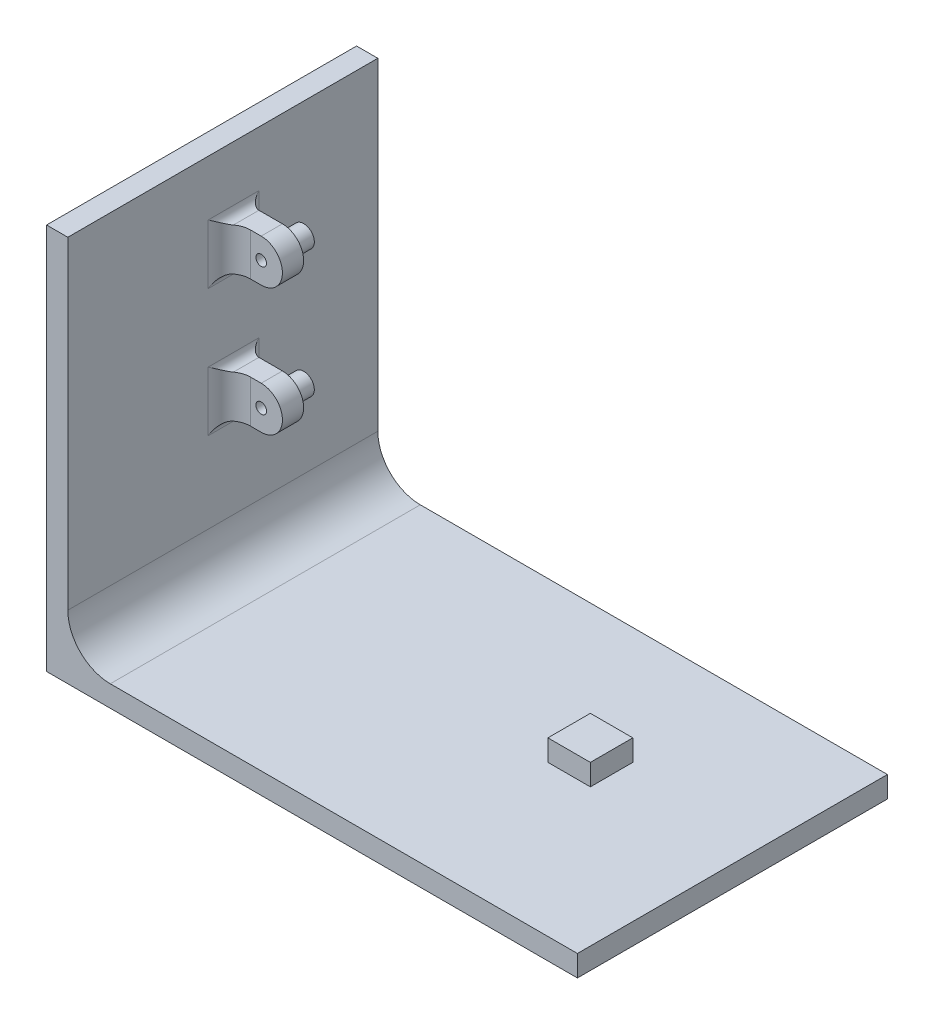
from build123d import *

# Parameters (mm, degrees)
SCHIZZO1_W                   = 5
SCHIZZO1_H                   = 70
ESTRUSIONE_ESTRUSIONE1_DEPTH = 70
ESTRUSIONE_ESTRUSIONE2_START = -35
ESTRUSIONE_ESTRUSIONE2_DEPTH = 5
SCHIZZO3_R                   = 2.5
ESTRUSIONE_ESTRUSIONE3_DEPTH = 5
SCHIZZO4_W                   = 130
SCHIZZO4_H                   = 70
ESTRUSIONE_ESTRUSIONE4_DEPTH = 5
SCHIZZO5_R                   = 1.25
TAGLIO_ESTRUSIONE1_DEPTH     = 46
ESTRUSIONE_ESTRUSIONE5_DEPTH = 3
RACCORDO1_R                  = 5
RACCORDO2_R                  = 5
RACCORDO3_R                  = 2
RACCORDO4_R                  = 2
TAGLIO_ESTRUSIONE2_REACH     = 75
SCHIZZO8_R                   = 1.25
SCHIZZO8_W                   = 144.941268382
SCHIZZO8_H                   = 14.939772921
TAGLIO_ESTRUSIONE3_DEPTH     = 74
SCHIZZO10_W                  = 5
SCHIZZO10_H                  = 73
ESTRUSIONE_ESTRUSIONE6_DEPTH = 31
SCHIZZO11_W                  = 73
SCHIZZO11_H                  = 5
ESTRUSIONE_ESTRUSIONE7_DEPTH = 120
RACCORDO5_R                  = 10
SCHIZZO12_W                  = 10
SCHIZZO12_H                  = 10
ESTRUSIONE_ESTRUSIONE8_DEPTH = 5


with BuildPart() as part:
    # Schizzo1 → Estrusione-Estrusione1 (new body)
    with BuildSketch(Plane.XY):
        with Locations((-2.5, 35)):
            Rectangle(SCHIZZO1_W, SCHIZZO1_H)
    extrude(amount=ESTRUSIONE_ESTRUSIONE1_DEPTH)

    # Schizzo2 → Estrusione-Estrusione2 (add)
    with BuildSketch(Plane.XY.offset(70).offset(ESTRUSIONE_ESTRUSIONE2_START)):
        with BuildLine():
            Line((0, 50), (0, 45))
            Line((0, 45), (7.531619243, 45))
            ThreePointArc((7.531619243, 45), (12.531619243, 50), (7.531619243, 55))
            Line((7.531619243, 55), (0, 55))
            Line((0, 55), (0, 50))
        make_face()
        with BuildLine():
            Line((0, 20), (0, 15))
            Line((0, 15), (7.531619243, 15))
            ThreePointArc((7.531619243, 15), (12.531619243, 20), (7.531619243, 25))
            Line((7.531619243, 25), (0, 25))
            Line((0, 25), (0, 20))
        make_face()
    extrude(amount=-ESTRUSIONE_ESTRUSIONE2_DEPTH)

    # Schizzo3 → Estrusione-Estrusione3 (add)
    with BuildSketch(Plane(origin=(0, 0, 30), x_dir=(-1, 0, 0), z_dir=(0, 0, -1))):
        with Locations((-7.547600082, 50.061310314)):
            Circle(SCHIZZO3_R)
        with Locations((-7.547600082, 19.939772921)):
            Circle(SCHIZZO3_R)
    extrude(amount=ESTRUSIONE_ESTRUSIONE3_DEPTH)

    # Schizzo4 → Estrusione-Estrusione4 (add)
    with BuildSketch(Plane.XZ):
        with Locations((60, 35)):
            Rectangle(SCHIZZO4_W, SCHIZZO4_H)
    extrude(amount=ESTRUSIONE_ESTRUSIONE4_DEPTH)

    # Schizzo5 → Taglio-Estrusione1 (cut, through all)
    with BuildSketch(Plane(origin=(0, 0, 25), x_dir=(-1, 0, 0), z_dir=(0, 0, -1))):
        with Locations((-7.547600082, 50.061310314)):
            Circle(SCHIZZO5_R)
        with Locations((-7.547600082, 19.939772921)):
            Circle(SCHIZZO5_R)
    extrude(amount=-TAGLIO_ESTRUSIONE1_DEPTH, mode=Mode.SUBTRACT)

    # Schizzo6 → Estrusione-Estrusione5 (add)
    with BuildSketch(Plane.XY.offset(70)):
        Polygon((125, 0), (0, 0), (0, 70), (-5, 70), (-5, -5), (125, -5), align=None)
        Polygon((0, 70), (125, 0), (0, 0), align=None)
    extrude(amount=ESTRUSIONE_ESTRUSIONE5_DEPTH)

    # Raccordo1
    raccordo1_edges = [part.edges().sort_by_distance(p)[0] for p in [
        (0, 35, 70),
        (62.5, 0, 70),
        (0, 0, 35),
    ]]
    fillet(raccordo1_edges, radius=RACCORDO1_R)

    # Raccordo2
    raccordo2_edges = [part.edges().sort_by_distance(p)[0] for p in [
        (0, 50, 35),
        (0, 20, 35),
    ]]
    fillet(raccordo2_edges, radius=RACCORDO2_R)

    # Raccordo3
    raccordo3_edges = [part.edges().sort_by_distance(p)[0] for p in [
        (0, 50, 30),
        (0, 20, 30),
    ]]
    fillet(raccordo3_edges, radius=RACCORDO3_R)

    # Raccordo4
    raccordo4_edges = [part.edges().sort_by_distance(p)[0] for p in [
        (0, 25, 32.5),
        (0, 15, 32.5),
        (0, 45, 32.5),
        (0, 55, 32.5),
    ]]
    fillet(raccordo4_edges, radius=RACCORDO4_R)

    # Schizzo7 → Taglio-Estrusione2 (cut, up to next)
    with BuildSketch(Plane(origin=(0, 0, 73), x_dir=(-1, 0, 0), z_dir=(0, 0, -1)), mode=Mode.PRIVATE) as taglio_estrusione2_sk1:
        with BuildLine():
            ThreePointArc((-5, 0), (-1.464466094, 1.464466094), (0, 5))
            Line((0, 5), (0, 70))
            Line((0, 70), (-125, 0))
            Line((-125, 0), (-5, 0))
        make_face()
    taglio_estrusione2_tool1 = extrude(taglio_estrusione2_sk1.sketch, amount=TAGLIO_ESTRUSIONE2_REACH, mode=Mode.PRIVATE) & part.part
    add(taglio_estrusione2_tool1.solids().sort_by_distance((41.716454, 23.360611, 73))[0], mode=Mode.SUBTRACT)

    # Schizzo8 → Taglio-Estrusione3 (cut, through all)
    with BuildSketch(Plane(origin=(0, 0, 0), x_dir=(-1, 0, 0), z_dir=(0, 0, -1))):
        with Locations((-7.547600082, 19.939772921)):
            Circle(SCHIZZO8_R)
        with Locations((-52.529365809, 2.469886461)):
            Rectangle(SCHIZZO8_W, SCHIZZO8_H)
    extrude(amount=-TAGLIO_ESTRUSIONE3_DEPTH, mode=Mode.SUBTRACT)

    # Schizzo10 → Estrusione-Estrusione6 (add)
    with BuildSketch(Plane.XZ.offset(-9.939772921)):
        with Locations((-2.5, 36.5)):
            Rectangle(SCHIZZO10_W, SCHIZZO10_H)
    extrude(amount=ESTRUSIONE_ESTRUSIONE6_DEPTH)

    # Schizzo11 → Estrusione-Estrusione7 (add)
    with BuildSketch(Plane(origin=(0, 0, 0), x_dir=(0, 0, -1), z_dir=(1, 0, 0))):
        with Locations((-36.5, -18.560227079)):
            Rectangle(SCHIZZO11_W, SCHIZZO11_H)
    extrude(amount=ESTRUSIONE_ESTRUSIONE7_DEPTH)

    # Raccordo5
    raccordo5_edges = [part.edges().sort_by_distance(p)[0] for p in [
        (0, -16.060227079, 36.5),
    ]]
    fillet(raccordo5_edges, radius=RACCORDO5_R)

    # Schizzo12 → Estrusione-Estrusione8 (add)
    with BuildSketch(Plane(origin=(0, -16.060227079, 0), x_dir=(1, 0, 0), z_dir=(0, 1, 0))):
        with Locations((82.547600082, -32.5)):
            Rectangle(SCHIZZO12_W, SCHIZZO12_H)
    extrude(amount=ESTRUSIONE_ESTRUSIONE8_DEPTH)


solid = part.part
